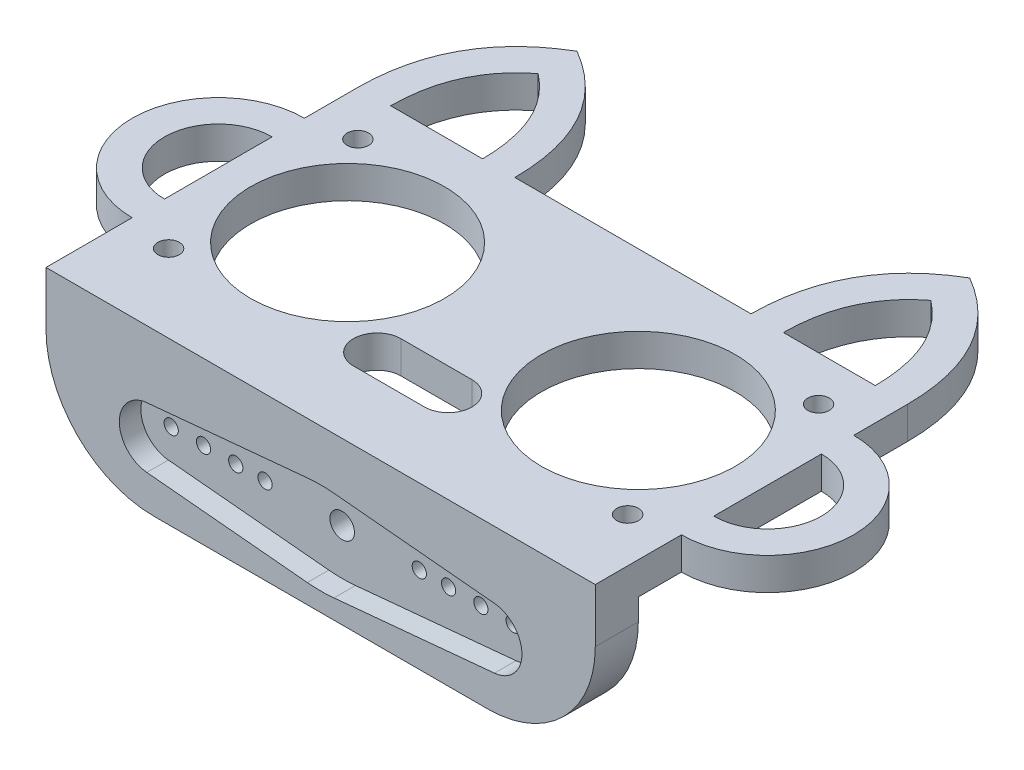
from build123d import *

# Parameters (mm, degrees)
SKETCH1_R           = 1
SKETCH1_R_2         = 9
BOSS_EXTRUDE3_DEPTH = 3
BOSS_EXTRUDE4_DEPTH = 15
SKETCH5_R           = 0.6604
SKETCH5_R_2         = 1.143
CUT_EXTRUDE1_DEPTH  = 10
FILLET2_R           = 10
CUT_EXTRUDE3_DEPTH  = 2
SKETCH8_W           = 10.76
SKETCH8_H           = 4
CUT_EXTRUDE4_DEPTH  = 1.3


with BuildPart() as part:
    # Sketch1 → Boss-Extrude3 (new body)
    with BuildSketch(Plane(origin=(0, 0, 0), x_dir=(1, 0, 0), z_dir=(0, 1, 0))):
        with BuildLine():
            Line((-25.5, -8), (-25.5, -13))
            Line((-25.5, -13), (25.5, -13))
            Line((25.5, -13), (25.5, -8))
            ThreePointArc((25.5, -8), (33.5, 0), (25.5, 8))
            Line((25.5, 8), (25.5, 13))
            add(Edge.make_bspline(
                [(25.5, 13), (25.447957122, 21.830633136), (18.232464907, 26.037260317)],
                knots=[0, 0, 0, 1, 1, 1], degree=2))
            add(Edge.make_bspline(
                [(10.964929815, 13), (11.016972693, 21.830633136), (18.232464907, 26.037260317)],
                knots=[0, 0, 0, 1, 1, 1], degree=2))
            Line((10.964929815, 13), (-10.964929815, 13))
            add(Edge.make_bspline(
                [(-10.964929815, 13), (-11.016972693, 21.830633136), (-18.232464907, 26.037260317)],
                knots=[0, 0, 0, 1, 1, 1], degree=2))
            add(Edge.make_bspline(
                [(-25.5, 13), (-25.447957122, 21.830633136), (-18.232464907, 26.037260317)],
                knots=[0, 0, 0, 1, 1, 1], degree=2))
            Line((-25.5, 13), (-25.5, 8))
            ThreePointArc((-25.5, 8), (-33.5, 0), (-25.5, -8))
        make_face()
        with Locations((-21.330701069, -8.788977071)):
            Circle(SKETCH1_R, mode=Mode.SUBTRACT)
        with BuildLine():
            ThreePointArc((-25.5, -5), (-30.5, 0), (-25.5, 5))
            Line((-25.5, 5), (-25.5, -5))
        make_face(mode=Mode.SUBTRACT)
        with Locations((-13.5, 0)):
            Circle(SKETCH1_R_2, mode=Mode.SUBTRACT)
        with BuildLine():
            ThreePointArc((-5.5, -7.45), (-4.855634919, -5.894365081), (-3.3, -5.25))
            Line((-3.3, -5.25), (3.3, -5.25))
            ThreePointArc((3.3, -5.25), (4.855634919, -5.894365081), (5.5, -7.45))
            ThreePointArc((5.5, -7.45), (4.855634919, -9.005634919), (3.3, -9.65))
            Line((3.3, -9.65), (-3.3, -9.65))
            ThreePointArc((-3.3, -9.65), (-4.855634919, -9.005634919), (-5.5, -7.45))
        make_face(mode=Mode.SUBTRACT)
        with Locations((21.36922293, -8.864067488)):
            Circle(SKETCH1_R, mode=Mode.SUBTRACT)
        with Locations((13.5, 0)):
            Circle(SKETCH1_R_2, mode=Mode.SUBTRACT)
        with BuildLine():
            Line((25.5, -5), (25.5, 5))
            ThreePointArc((25.5, 5), (30.5, 0), (25.5, -5))
        make_face(mode=Mode.SUBTRACT)
        with Locations((-21.330701069, 8.788977071)):
            Circle(SKETCH1_R, mode=Mode.SUBTRACT)
        with BuildLine():
            add(Edge.make_bspline(
                [(-18.232464907, 22.430397358), (-17.881752173, 22.15826664), (-17.197190326, 21.563514811), (-16.070323369, 20.318879343), (-15.204967784, 18.922941442), (-14.583600481, 17.329273987), (-14.239247895, 16.018289812), (-14.058547206, 14.81714331), (-13.98211291, 13.800154377), (-13.966795322, 13.26237878), (-13.964990622, 12.999999994)],
                knots=[0, 0, 0, 0, 0.107910014, 0.215820028, 0.431640056, 0.53955007, 0.647460084, 0.755370098, 0.809325105, 0.862094482, 0.862094482, 0.862094482, 0.862094482], degree=3))
            Line((-13.964990622, 12.999999994), (-22.499939192, 12.999999994))
            add(Edge.make_bspline(
                [(-22.499939192, 12.999999994), (-22.498134493, 13.26237878), (-22.482816904, 13.800154377), (-22.406382608, 14.81714331), (-22.22568192, 16.018289812), (-21.881329334, 17.329273987), (-21.259962031, 18.922941442), (-20.394606445, 20.318879343), (-19.267739489, 21.563514811), (-18.583177642, 22.15826664), (-18.232464907, 22.430397358)],
                knots=[0.00118563, 0.00118563, 0.00118563, 0.00118563, 0.053955007, 0.107910014, 0.215820028, 0.323730042, 0.431640056, 0.647460084, 0.755370098, 0.863280112, 0.863280112, 0.863280112, 0.863280112], degree=3))
        make_face(mode=Mode.SUBTRACT)
        with Locations((21.36922293, 8.864067488)):
            Circle(SKETCH1_R, mode=Mode.SUBTRACT)
        with BuildLine():
            Line((22.499939192, 13), (13.964990622, 13))
            add(Edge.make_bspline(
                [(13.964990622, 13), (13.966795322, 13.262378784), (13.982112911, 13.800154379), (14.058547206, 14.81714331), (14.239247895, 16.018289812), (14.583600481, 17.329273987), (15.204967784, 18.922941442), (16.070323369, 20.318879343), (17.197190326, 21.563514811), (17.881752173, 22.15826664), (18.232464907, 22.430397358)],
                knots=[0.00118563, 0.00118563, 0.00118563, 0.00118563, 0.053955007, 0.107910014, 0.215820028, 0.323730042, 0.431640056, 0.647460084, 0.755370098, 0.863280112, 0.863280112, 0.863280112, 0.863280112], degree=3))
            add(Edge.make_bspline(
                [(18.232464907, 22.430397358), (18.583177642, 22.15826664), (19.267739489, 21.563514811), (20.394606445, 20.318879343), (21.259962031, 18.922941442), (21.881329334, 17.329273987), (22.22568192, 16.018289812), (22.406382608, 14.81714331), (22.482816904, 13.800154379), (22.498134493, 13.262378784), (22.499939192, 13)],
                knots=[0, 0, 0, 0, 0.107910014, 0.215820028, 0.431640056, 0.53955007, 0.647460084, 0.755370098, 0.809325105, 0.862094482, 0.862094482, 0.862094482, 0.862094482], degree=3))
        make_face(mode=Mode.SUBTRACT)
    extrude(amount=BOSS_EXTRUDE3_DEPTH)

    # Sketch4 → Boss-Extrude4 (add)
    with BuildSketch(Plane(origin=(0, 3, 0), x_dir=(1, 0, 0), z_dir=(0, 1, 0))):
        Polygon((-25.5, -13), (-25.5, -16), (25.5, -16), (25.5, -13), (25.5, -12), (-25.5, -12), align=None)
    extrude(amount=-BOSS_EXTRUDE4_DEPTH)

    # Sketch5 → Cut-Extrude1 (cut)
    with BuildSketch(Plane(origin=(0, 0, 12), x_dir=(-1, 0, 0), z_dir=(0, 0, -1))):
        with Locations((-15.875, -6)):
            Circle(SKETCH5_R)
        with Locations((-12.8778, -6)):
            Circle(SKETCH5_R)
        with Locations((-9.8806, -6)):
            Circle(SKETCH5_R)
        with Locations((-7.1628, -6)):
            Circle(SKETCH5_R)
        with Locations((15.875, -6)):
            Circle(SKETCH5_R)
        with Locations((12.8778, -6)):
            Circle(SKETCH5_R)
        with Locations((9.8806, -6)):
            Circle(SKETCH5_R)
        with Locations((7.1628, -6)):
            Circle(SKETCH5_R)
        with Locations((0, -6)):
            Circle(SKETCH5_R_2)
    extrude(amount=-CUT_EXTRUDE1_DEPTH, mode=Mode.SUBTRACT)

    # Fillet2
    fillet2_edges = [part.edges().sort_by_distance(p)[0] for p in [
        (25.5, -12, 14),
        (-25.5, -12, 14),
    ]]
    fillet(fillet2_edges, radius=FILLET2_R)

    # Sketch7 → Cut-Extrude3 (cut)
    with BuildSketch(Plane.XY.offset(16)):
        with BuildLine():
            Line((1.237363975, -10.208408252), (16.139135026, -8.805342715))
            ThreePointArc((16.139135026, -8.805342715), (18.69275, -6), (16.139135026, -3.194657285))
            Line((16.139135026, -3.194657285), (1.237363975, -1.791591748))
            ThreePointArc((1.237363975, -1.791591748), (0, -1.733468722), (-1.237363975, -1.791591748))
            Line((-1.237363975, -1.791591748), (-16.139135026, -3.194657285))
            ThreePointArc((-16.139135026, -3.194657285), (-18.69275, -6), (-16.139135026, -8.805342715))
            Line((-16.139135026, -8.805342715), (-1.237363975, -10.208408252))
            ThreePointArc((-1.237363975, -10.208408252), (0, -10.266531278), (1.237363975, -10.208408252))
        make_face()
    extrude(amount=-CUT_EXTRUDE3_DEPTH, mode=Mode.SUBTRACT)

    # Sketch8 → Cut-Extrude4 (cut)
    with BuildSketch(Plane.XZ):
        with Locations((0, -8.7)):
            Rectangle(SKETCH8_W, SKETCH8_H)
    extrude(amount=-CUT_EXTRUDE4_DEPTH, mode=Mode.SUBTRACT)


solid = part.part
